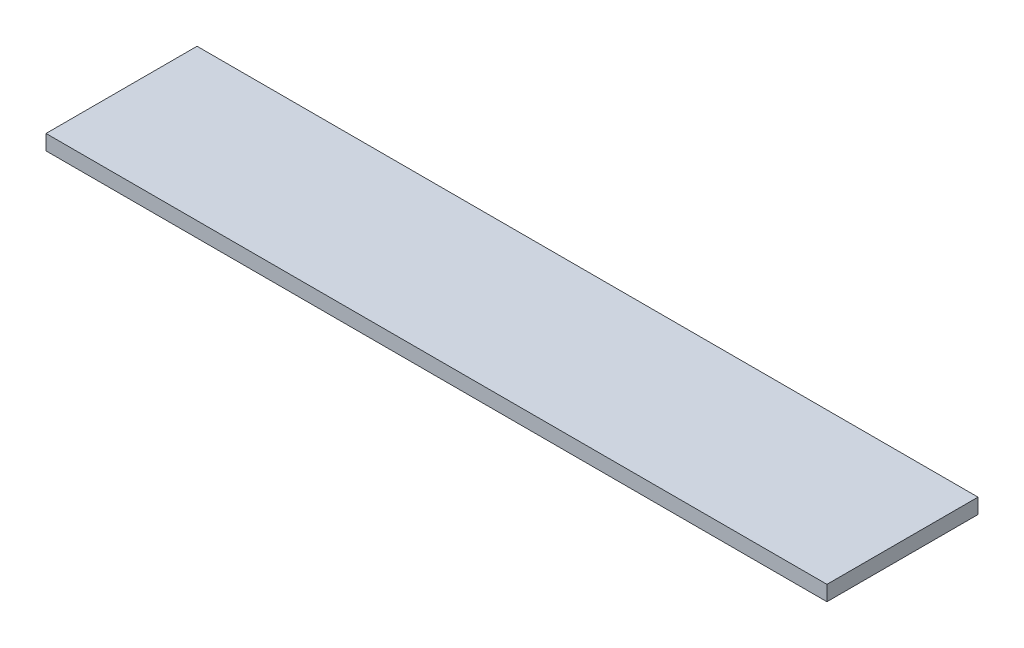
from build123d import *

# Parameters (mm, degrees)
ESQUISSE1_W      = 517
ESQUISSE1_H      = 100
EXTRUSION1_DEPTH = 10


with BuildPart() as part:
    # Esquisse1 → Extrusion1 (new body)
    with BuildSketch(Plane(origin=(0, 0, 0), x_dir=(1, 0, 0), z_dir=(0, 1, 0))):
        with Locations((258.5, 50)):
            Rectangle(ESQUISSE1_W, ESQUISSE1_H)
    extrude(amount=EXTRUSION1_DEPTH)


solid = part.part
